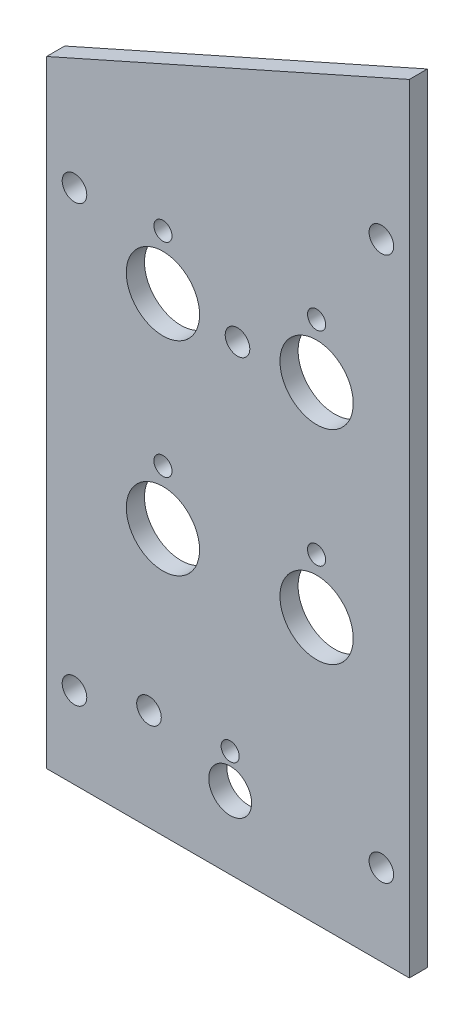
from build123d import *

# Parameters (mm, degrees)
BOSS_EXTRUDE1_DEPTH   = 3.175
F_6_CLEARANCE_HOLE1_D = 4.3053
SKETCH8_R             = 1.5875
SKETCH8_R_2           = 3.75
SKETCH8_R_3           = 6.4135
CUT_EXTRUDE1_DEPTH    = 4.175
F_6_CLEARANCE_HOLE2_D = 4.3053


with BuildPart() as part:
    # Sketch1 → Boss-Extrude1 (new body)
    with BuildSketch(Plane.XY):
        Polygon((0, 107.95), (0, 0), (63.5, 0), (63.5, 136.2202), align=None)
    extrude(amount=-BOSS_EXTRUDE1_DEPTH)

    # #6 Clearance Hole1 (through all)
    with Locations(Plane.XY):
        with Locations((58.6105, 14.2875), (4.8895, 14.2875), (4.8895, 90.4875), (58.6105, 109.5375)):
            Hole(F_6_CLEARANCE_HOLE1_D / 2)

    # Sketch8 → Cut-Extrude1 (cut, through all)
    with BuildSketch(Plane.XY):
        with Locations((20.373230618, 91.71042385)):
            Circle(SKETCH8_R)
        with Locations((47.270485986, 91.71042385)):
            Circle(SKETCH8_R)
        with Locations((47.270485986, 56.073006151)):
            Circle(SKETCH8_R)
        with Locations((32.1439032, 12.7)):
            Circle(SKETCH8_R_2)
        with Locations((20.373230618, 56.073006151)):
            Circle(SKETCH8_R)
        with Locations((32.1439032, 18.7)):
            Circle(SKETCH8_R)
        with Locations((47.270485986, 46.548006151)):
            Circle(SKETCH8_R_3)
        with Locations((47.270485986, 82.18542385)):
            Circle(SKETCH8_R_3)
        with Locations((20.373230618, 82.18542385)):
            Circle(SKETCH8_R_3)
        with Locations((20.373230618, 46.548006151)):
            Circle(SKETCH8_R_3)
    extrude(amount=-CUT_EXTRUDE1_DEPTH, mode=Mode.SUBTRACT)

    # #6 Clearance Hole2 (through all)
    with Locations(Plane(origin=(31.75, 0, 6.35), x_dir=(1, 0, 0), z_dir=(0, 0, 1))):
        with Locations((1.676331213, 81.383391323), (-13.818696068, 17.771227958)):
            Hole(F_6_CLEARANCE_HOLE2_D / 2)


solid = part.part
